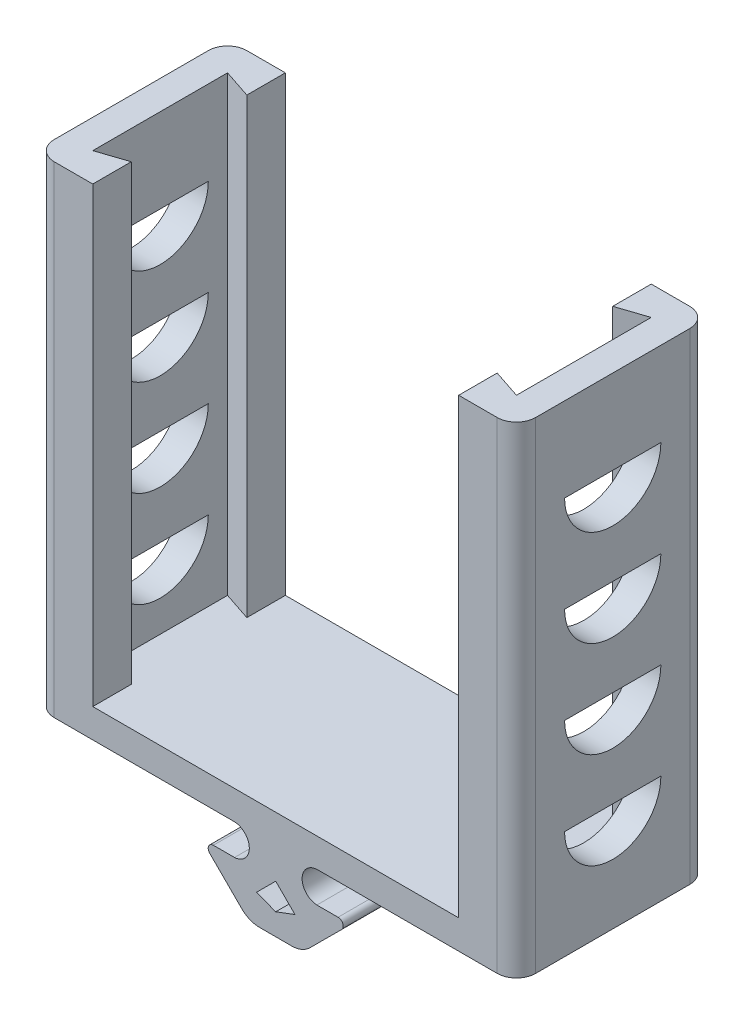
from build123d import *

# Parameters (mm, degrees)
BOSS_EXTRUDE1_DEPTH  = 20
BOSS_EXTRUDE2_DEPTH  = 50
CUT_EXTRUDE1_DEPTH   = 47
CUT_EXTRUDE2_DEPTH   = 4
LPATTERN1_COUNT      = 4
LPATTERN1_PITCH      = 10
MIRROR2_COPY_1_DEPTH = 4
MIRROR2_COPY_2_DEPTH = 4
MIRROR2_COPY_3_DEPTH = 4
CUT_EXTRUDE3_DEPTH   = 30


with BuildPart() as part:
    # Sketch1 → Boss-Extrude1 (new body)
    with BuildSketch(Plane.XY):
        with BuildLine():
            ThreePointArc((-4.288832517, 8.7042), (-2.742571539, 7.105968455), (-4.274927306, 5.4944))
            Line((-4.274927306, 5.4944), (-6.476788598, 5.4944))
            ThreePointArc((-6.476788598, 5.4944), (-6.970173245, 5.164526769), (-6.853887321, 4.582528193))
            Line((-6.853887321, 4.582528193), (-3.545123878, 1.281326675))
            ThreePointArc((-3.545123878, 1.281326675), (-2.678042762, 0.703037101), (-1.655778399, 0.5))
            Line((-1.655778399, 0.5), (0, 0.5))
            Line((0, 0.5), (0, 8.7042))
            Line((0, 8.7042), (-4.288832517, 8.7042))
        make_face()
    boss_extrude1 = extrude(amount=BOSS_EXTRUDE1_DEPTH)

    # Sketch2 → Boss-Extrude2 (add)
    with BuildSketch(Plane(origin=(0, 8.7042, 0), x_dir=(1, 0, 0), z_dir=(0, 1, 0))):
        with BuildLine():
            Line((0, -20), (-23, -20))
            ThreePointArc((-23, -20), (-24.414213562, -19.414213562), (-25, -18))
            Line((-25, -18), (-25, -2))
            ThreePointArc((-25, -2), (-24.414213562, -0.585786438), (-23, 0))
            Line((-23, 0), (0, 0))
            Line((0, 0), (0, -20))
        make_face()
    boss_extrude2 = extrude(amount=BOSS_EXTRUDE2_DEPTH)

    # Sketch4 → Cut-Extrude1 (cut)
    with BuildSketch(Plane(origin=(0, 58.7042, 0), x_dir=(1, 0, 0), z_dir=(0, 1, 0))):
        Polygon((-22, -17), (-22, -3), (-19, -4), (-19, 0), (0, 0), (0, -20), (-19, -20), (-19, -16), align=None)
    cut_extrude1 = extrude(amount=-CUT_EXTRUDE1_DEPTH, mode=Mode.SUBTRACT)

    # Sketch6 → Cut-Extrude2 (cut, through all)
    with BuildSketch(Plane(origin=(-22, 0, 0), x_dir=(0, 0, -1), z_dir=(1, 0, 0))):
        with BuildLine():
            Line((-15, 19.9542), (-5, 19.9542))
            ThreePointArc((-5, 19.9542), (-10, 14.9542), (-15, 19.9542))
        make_face()
    cut_extrude2 = extrude(amount=-CUT_EXTRUDE2_DEPTH, mode=Mode.SUBTRACT)

    # LPattern1: Cut-Extrude2 ×4
    with Locations(*[(0, i * LPATTERN1_PITCH, 0) for i in range(1, LPATTERN1_COUNT)]):
        add(cut_extrude2, mode=Mode.SUBTRACT)

    # Mirror2: Boss-Extrude1, Boss-Extrude2, Cut-Extrude1, Cut-Extrude2 across Right Plane
    add(boss_extrude1.mirror(Plane(origin=(0, 0, 0), x_dir=(0, 0, -1), z_dir=(1, 0, 0))))
    add(boss_extrude2.mirror(Plane(origin=(0, 0, 0), x_dir=(0, 0, -1), z_dir=(1, 0, 0))))
    add(cut_extrude1.mirror(Plane(origin=(0, 0, 0), x_dir=(0, 0, -1), z_dir=(1, 0, 0))), mode=Mode.SUBTRACT)
    add(cut_extrude2.mirror(Plane(origin=(0, 0, 0), x_dir=(0, 0, -1), z_dir=(1, 0, 0))), mode=Mode.SUBTRACT)

    # Mirror2 copy 1 sketch → Mirror2 copy 1 (cut, through all)
    with BuildSketch(Plane(origin=(22, 10, 0), x_dir=(0, 0, -1), z_dir=(-1, 0, 0))):
        with BuildLine():
            Line((-15, -19.9542), (-5, -19.9542))
            ThreePointArc((-5, -19.9542), (-10, -14.9542), (-15, -19.9542))
        make_face()
    extrude(amount=-MIRROR2_COPY_1_DEPTH, mode=Mode.SUBTRACT)

    # Mirror2 copy 2 sketch → Mirror2 copy 2 (cut, through all)
    with BuildSketch(Plane(origin=(22, 20, 0), x_dir=(0, 0, -1), z_dir=(-1, 0, 0))):
        with BuildLine():
            Line((-15, -19.9542), (-5, -19.9542))
            ThreePointArc((-5, -19.9542), (-10, -14.9542), (-15, -19.9542))
        make_face()
    extrude(amount=-MIRROR2_COPY_2_DEPTH, mode=Mode.SUBTRACT)

    # Mirror2 copy 3 sketch → Mirror2 copy 3 (cut, through all)
    with BuildSketch(Plane(origin=(22, 30, 0), x_dir=(0, 0, -1), z_dir=(-1, 0, 0))):
        with BuildLine():
            Line((-15, -19.9542), (-5, -19.9542))
            ThreePointArc((-5, -19.9542), (-10, -14.9542), (-15, -19.9542))
        make_face()
    extrude(amount=-MIRROR2_COPY_3_DEPTH, mode=Mode.SUBTRACT)

    # Sketch7 → Cut-Extrude3 (cut)
    with BuildSketch(Plane.XY.offset(20)):
        Polygon((-2, 3.5), (0, 5.5), (2, 3.5), (0, 2.75), align=None)
    extrude(amount=-CUT_EXTRUDE3_DEPTH, mode=Mode.SUBTRACT)


solid = part.part
